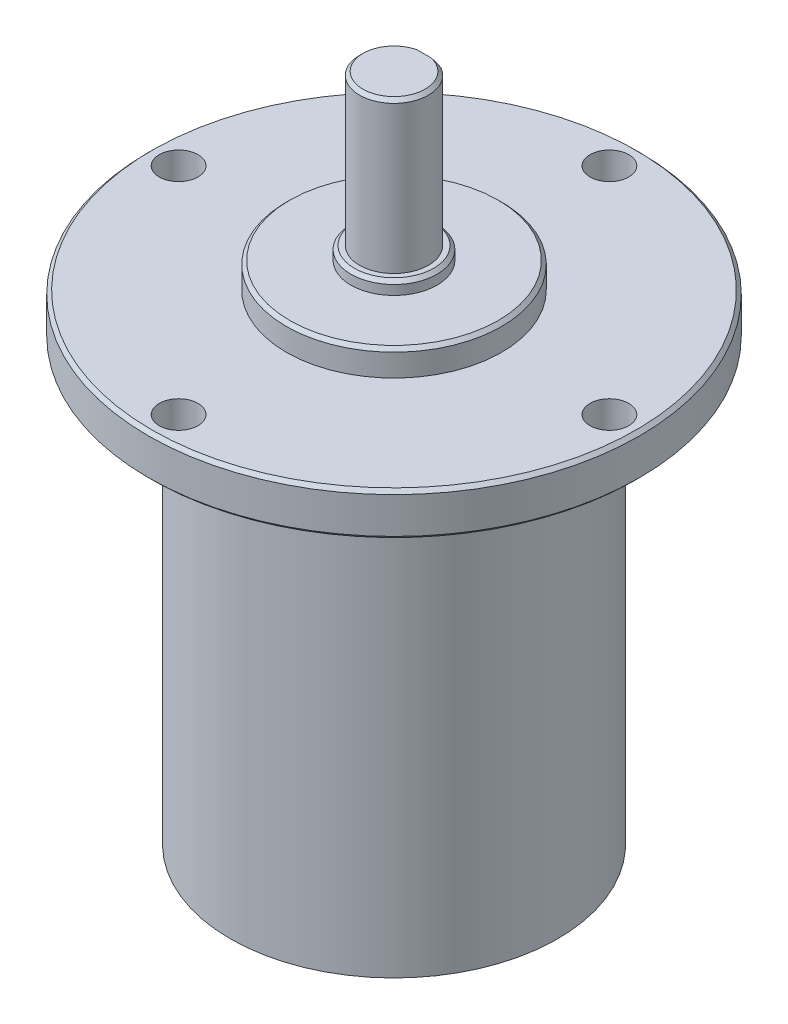
from build123d import *

# Parameters (mm, degrees)
BOSS_EXTRUDE1_DEPTH = 17.5
SKETCH3_R           = 2.25
CUT_EXTRUDE1_DEPTH  = 56.7
CHAMFER1_SIZE       = 0.4
CHAMFER2_SIZE       = 0.4
CHAMFER3_SIZE       = 0.4


with BuildPart() as part:
    # Sketch1 → Revolve1 (revolve)
    with BuildSketch(Plane.XY):
        Polygon((0, 0), (-19, 0), (-19, 50.7), (-28.5, 50.7), (-28.5, 55.7), (-12.5, 55.7), (-12.5, 58.7), (-5, 58.7), (-5, 60.2), (0, 60.2), align=None)
    revolve(axis=Axis((0, 60.2, 0), (0, -1, 0)))

    # Sketch2 → Boss-Extrude1 (add)
    with BuildSketch(Plane(origin=(0, 60.2, 0), x_dir=(1, 0, 0), z_dir=(0, 1, 0))):
        with BuildLine():
            Line((-1.936491673, 3.5), (1.936491673, 3.5))
            ThreePointArc((1.936491673, 3.5), (0, -4), (-1.936491673, 3.5))
        make_face()
    extrude(amount=BOSS_EXTRUDE1_DEPTH)

    # Sketch3 → Cut-Extrude1 (cut, through all)
    with BuildSketch(Plane(origin=(0, 55.7, 0), x_dir=(1, 0, 0), z_dir=(0, 1, 0))):
        with Locations((-25, 0)):
            Circle(SKETCH3_R)
        with Locations((0, 25)):
            Circle(SKETCH3_R)
        with Locations((25, 0)):
            Circle(SKETCH3_R)
        with Locations((0, -25)):
            Circle(SKETCH3_R)
    extrude(amount=-CUT_EXTRUDE1_DEPTH, mode=Mode.SUBTRACT)

    # Chamfer1
    chamfer1_edges = [part.edges().sort_by_distance(p)[0] for p in [
        (28.5, 55.7, 0),
        (28.5, 50.7, 0),
        (12.5, 58.7, 0),
    ]]
    chamfer(chamfer1_edges, length=CHAMFER1_SIZE)

    # Chamfer2
    chamfer2_edges = [part.edges().sort_by_distance(p)[0] for p in [
        (0, 77.7, 4),
    ]]
    chamfer(chamfer2_edges, length=CHAMFER2_SIZE)

    # Chamfer3
    chamfer3_edges = [part.edges().sort_by_distance(p)[0] for p in [
        (5, 60.2, 0),
    ]]
    chamfer(chamfer3_edges, length=CHAMFER3_SIZE)


solid = part.part
